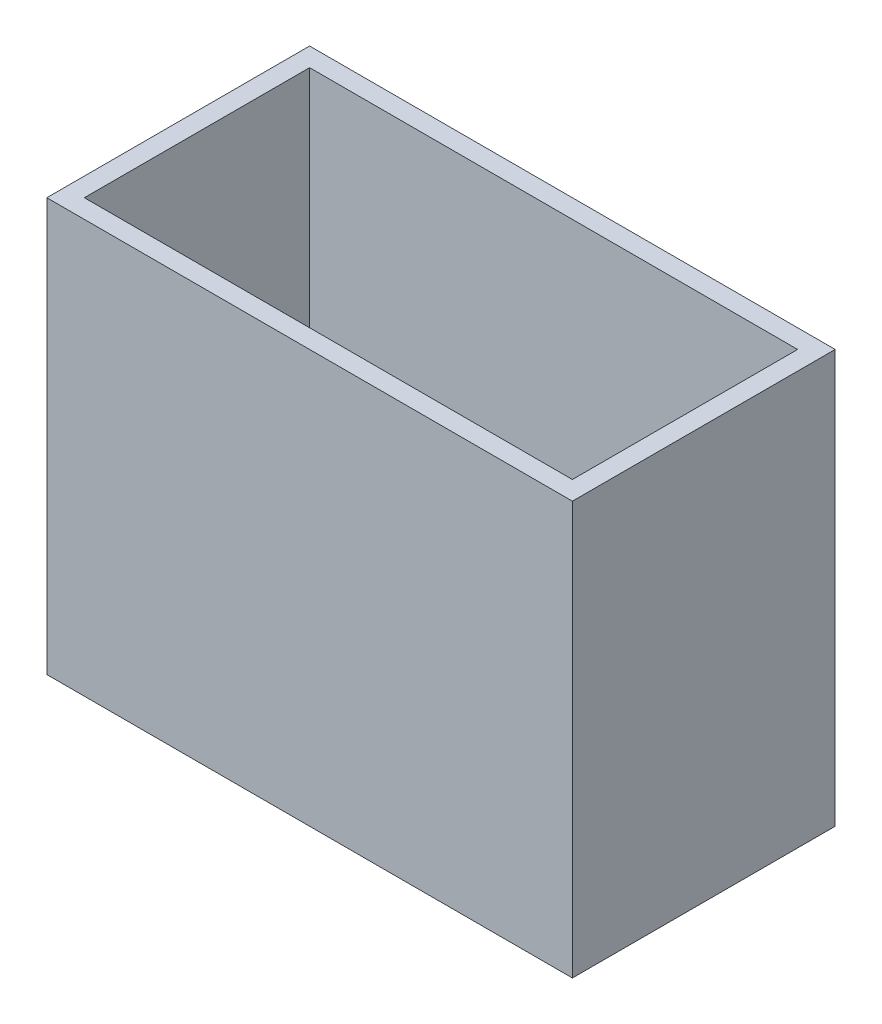
from build123d import *

# Parameters (mm, degrees)
SKETCH1_W           = 14
SKETCH1_H           = 7
SKETCH1_W_2         = 13
SKETCH1_H_2         = 6
BOSS_EXTRUDE1_DEPTH = 5.5


with BuildPart() as part:
    # Sketch1 → Boss-Extrude1 (new body, symmetric)
    with BuildSketch(Plane(origin=(0, 0, 0), x_dir=(1, 0, 0), z_dir=(0, 1, 0))):
        Rectangle(SKETCH1_W, SKETCH1_H)
        Rectangle(SKETCH1_W_2, SKETCH1_H_2, mode=Mode.SUBTRACT)
    extrude(amount=BOSS_EXTRUDE1_DEPTH, both=True)


solid = part.part
